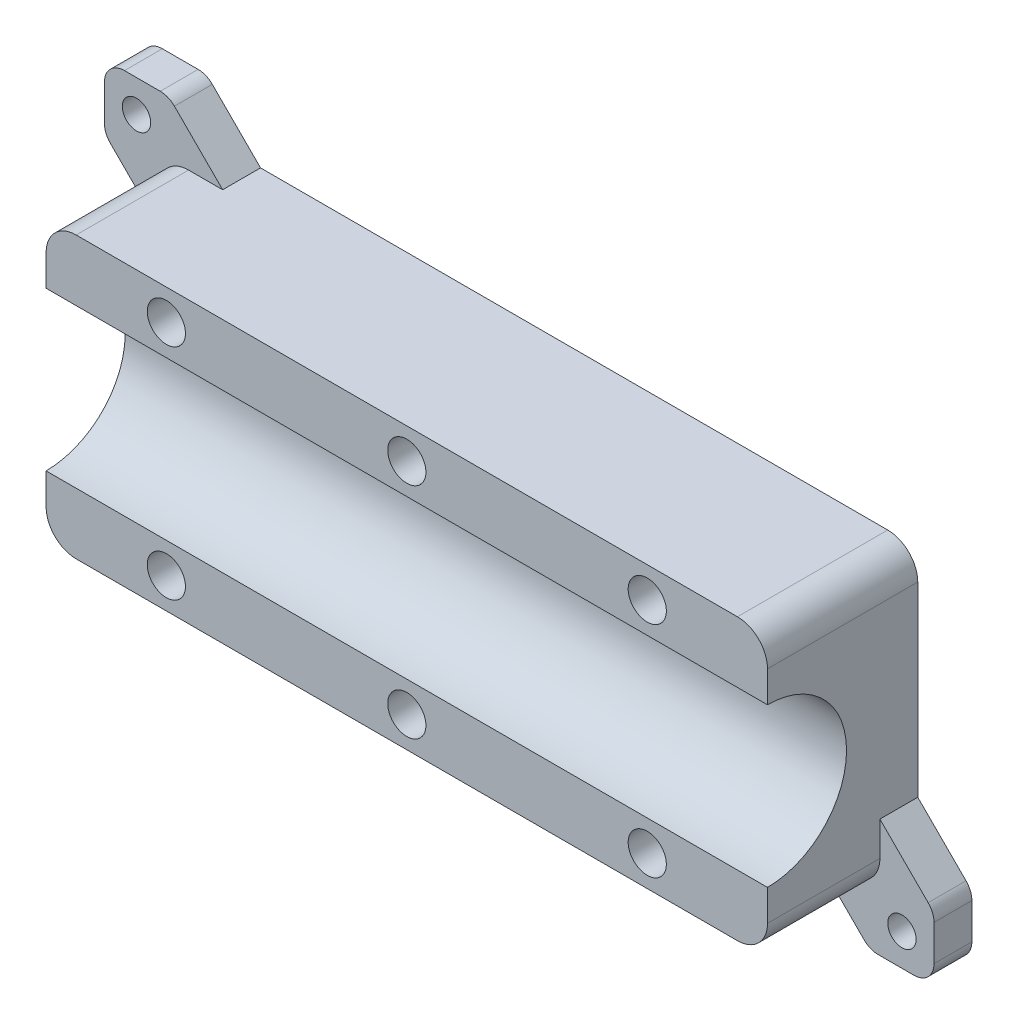
from build123d import *

# Parameters (mm, degrees)
SKETCH1_W               = 114.3
SKETCH1_H               = 44.45
BOSS_EXTRUDE1_DEPTH     = 5
BOSS_EXTRUDE2_DEPTH     = 114.3
SKETCH3_R               = 3.025
CUT_EXTRUDE1_DEPTH      = 8
LPATTERN1_COUNT         = 2
LPATTERN1_PITCH         = 38.1
LPATTERN1_COL_COUNT     = 2
LPATTERN1_COL_PITCH     = 38.1
MIRROR1_COPY_1_SKETCH_R = 3.025
MIRROR1_COPY_1_DEPTH    = 8
MIRROR1_COPY_2_SKETCH_R = 3.025
MIRROR1_COPY_2_DEPTH    = 8
SKETCH4_W               = 10.16
SKETCH4_H               = 10.16
BOSS_EXTRUDE3_DEPTH     = 6
M4_CLEARANCE_HOLE1_D    = 4.5
FILLET3_R               = 3.175
FILLET4_R               = 4.7625


with BuildPart() as part:
    # Sketch1 → Boss-Extrude1 (new body)
    with BuildSketch(Plane.XY):
        Rectangle(SKETCH1_W, SKETCH1_H)
    extrude(amount=BOSS_EXTRUDE1_DEPTH)

    # Sketch2 → Boss-Extrude2 (add)
    with BuildSketch(Plane.ZY.offset(57.15)):
        with BuildLine():
            Line((23.8125, 22.225), (5, 22.225))
            Line((5, 22.225), (5, -22.225))
            Line((5, -22.225), (23.8125, -22.225))
            Line((23.8125, -22.225), (23.8125, -12.5269))
            ThreePointArc((23.8125, -12.5269), (11.2856, 0), (23.8125, 12.5269))
            Line((23.8125, 12.5269), (23.8125, 22.225))
        make_face()
    extrude(amount=-BOSS_EXTRUDE2_DEPTH)

    # Sketch3 → Cut-Extrude1 (cut)
    with BuildSketch(Plane.XY.offset(23.8125)):
        with Locations((0, 17.37595)):
            Circle(SKETCH3_R)
    cut_extrude1 = extrude(amount=-CUT_EXTRUDE1_DEPTH, mode=Mode.SUBTRACT)

    # LPattern1: Cut-Extrude1 ×2
    with Locations(*[(i * LPATTERN1_PITCH, 0, 0) for i in range(1, LPATTERN1_COUNT)]):
        add(cut_extrude1, mode=Mode.SUBTRACT)

    # LPattern1 col: Cut-Extrude1 ×2
    with Locations(*[(-i * LPATTERN1_COL_PITCH, 0, 0) for i in range(1, LPATTERN1_COL_COUNT)]):
        add(cut_extrude1, mode=Mode.SUBTRACT)

    # Mirror1: Cut-Extrude1 across plane
    add(cut_extrude1.mirror(Plane.ZX), mode=Mode.SUBTRACT)

    # Mirror1 copy 1 sketch → Mirror1 copy 1 (cut)
    with BuildSketch(Plane(origin=(38.1, 0, 23.8125), x_dir=(1, 0, 0), z_dir=(0, 0, 1))):
        with Locations((0, -17.37595)):
            Circle(MIRROR1_COPY_1_SKETCH_R)
    extrude(amount=-MIRROR1_COPY_1_DEPTH, mode=Mode.SUBTRACT)

    # Mirror1 copy 2 sketch → Mirror1 copy 2 (cut)
    with BuildSketch(Plane(origin=(-38.1, 0, 23.8125), x_dir=(1, 0, 0), z_dir=(0, 0, 1))):
        with Locations((0, -17.37595)):
            Circle(MIRROR1_COPY_2_SKETCH_R)
    extrude(amount=-MIRROR1_COPY_2_DEPTH, mode=Mode.SUBTRACT)

    # Sketch4 → Boss-Extrude3 (add)
    with BuildSketch(Plane.XY):
        Polygon((-65.7225, 30.7975), (-55.5625, 20.6375), (-65.7225, 20.6375), align=None)
        Polygon((-65.7225, 30.7975), (-55.5625, 30.7975), (-55.5625, 20.6375), align=None)
        with Locations((60.6425, -25.7175)):
            Rectangle(SKETCH4_W, SKETCH4_H)
        Polygon((-55.5625, 30.7975), (-60.6425, 25.7175), (-57.15, 22.225), (-55.5625, 22.225), align=None)
        Polygon((-46.99, 22.225), (-55.5625, 30.7975), (-55.5625, 22.225), align=None)
        Polygon((-60.6425, 25.7175), (-65.7225, 20.6375), (-57.15, 20.6375), (-57.15, 22.225), align=None)
        Polygon((-57.15, 20.6375), (-65.7225, 20.6375), (-57.15, 12.065), align=None)
        Polygon((57.15, -20.6375), (65.7225, -20.6375), (57.15, -12.065), align=None)
        Polygon((46.99, -22.225), (55.5625, -30.7975), (55.5625, -22.225), align=None)
    extrude(amount=BOSS_EXTRUDE3_DEPTH)

    # M4 Clearance Hole1 (through all)
    with Locations(Plane.XY.offset(6)):
        with Locations((-60.6425, 25.7175), (60.6425, -25.7175)):
            Hole(M4_CLEARANCE_HOLE1_D / 2)

    # Fillet3
    fillet3_edges = [part.edges().sort_by_distance(p)[0] for p in [
        (-55.5625, 30.7975, 3),
        (-65.7225, 30.7975, 3),
        (-65.7225, 20.6375, 3),
        (55.5625, -30.7975, 3),
        (65.7225, -30.7975, 3),
        (65.7225, -20.6375, 3),
    ]]
    fillet(fillet3_edges, radius=FILLET3_R)

    # Fillet4
    fillet4_edges = [part.edges().sort_by_distance(p)[0] for p in [
        (57.15, -22.225, 14.90625),
        (-57.15, -22.225, 11.90625),
        (-57.15, 22.225, 14.90625),
        (57.15, 22.225, 11.90625),
    ]]
    fillet(fillet4_edges, radius=FILLET4_R)


solid = part.part
